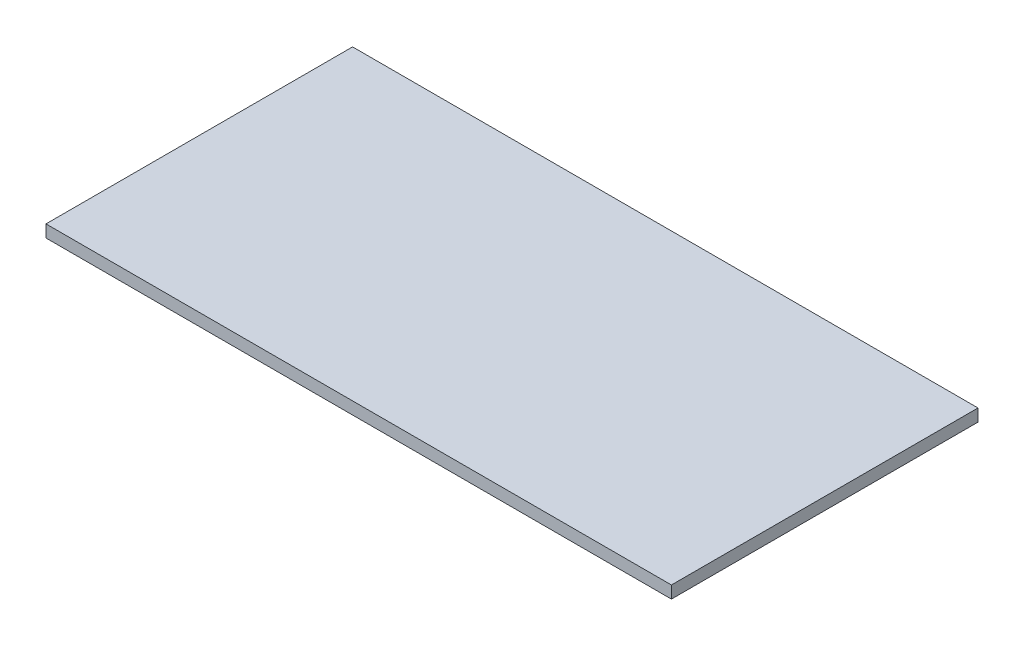
from build123d import *

# Parameters (mm, degrees)
SKETCH1_W           = 647.7
SKETCH1_H           = 317.5
BOSS_EXTRUDE1_DEPTH = 12.7


with BuildPart() as part:
    # Sketch1 → Boss-Extrude1 (new body)
    with BuildSketch(Plane(origin=(0, 0, 0), x_dir=(1, 0, 0), z_dir=(0, 1, 0))):
        with Locations((-38.605752212, -0.936578171)):
            Rectangle(SKETCH1_W, SKETCH1_H)
    extrude(amount=BOSS_EXTRUDE1_DEPTH)


solid = part.part
